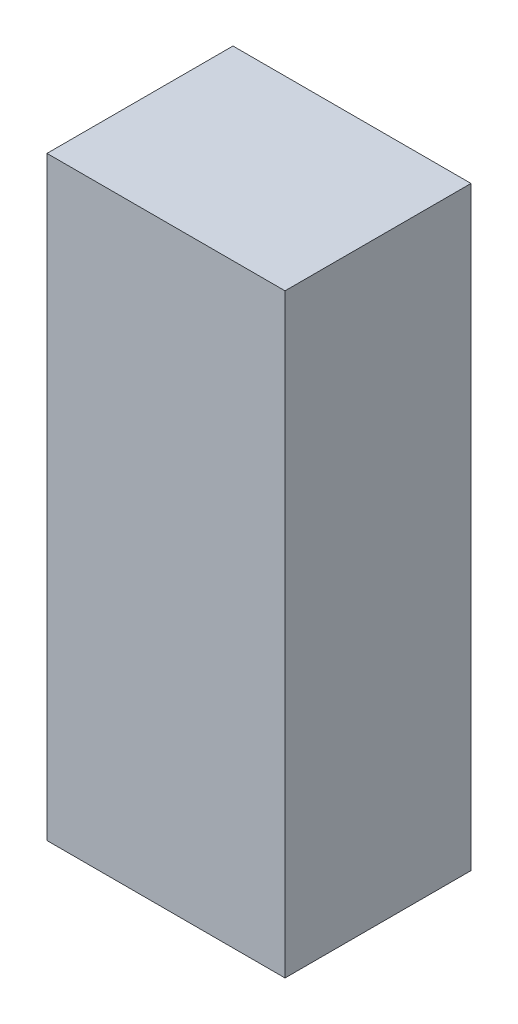
from build123d import *

# Parameters (mm, degrees)
SKETCH1_W           = 32
SKETCH1_H           = 80
BOSS_EXTRUDE1_DEPTH = 25


with BuildPart() as part:
    # Sketch1 → Boss-Extrude1 (new body)
    with BuildSketch(Plane.XY):
        Rectangle(SKETCH1_W, SKETCH1_H)
    extrude(amount=BOSS_EXTRUDE1_DEPTH)


solid = part.part
